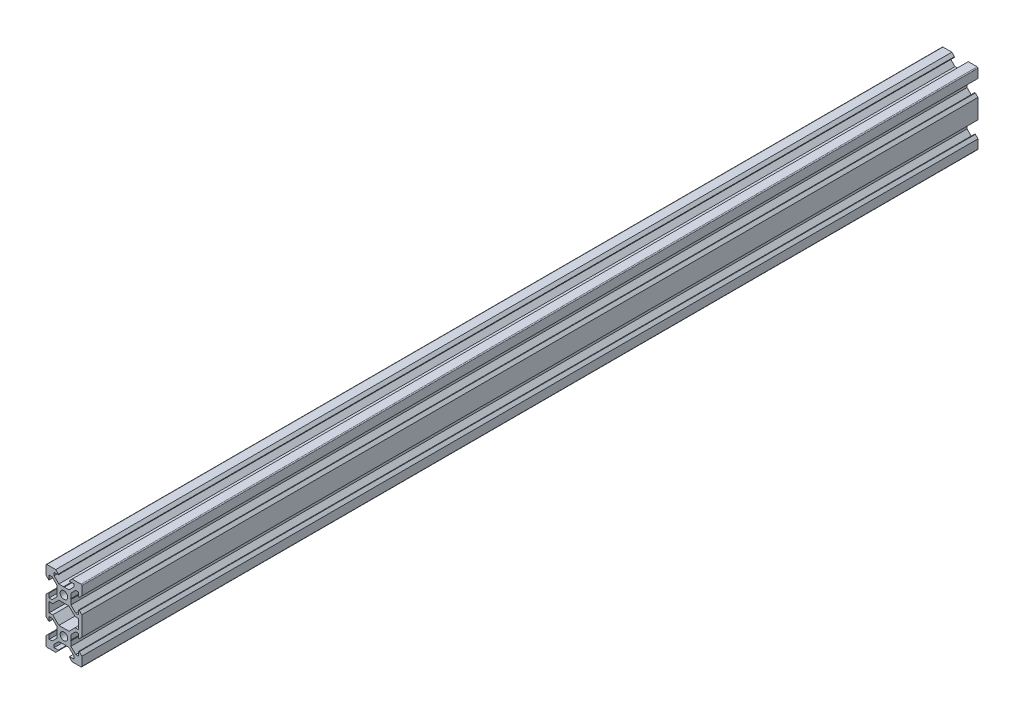
from build123d import *

# Parameters (mm, degrees)
SKETCH1_R           = 2.1
BOSS_EXTRUDE1_DEPTH = 500


with BuildPart() as part:
    # Sketch1 → Boss-Extrude1 (new body)
    with BuildSketch(Plane.XY):
        with BuildLine():
            Line((4.58, -20), (9.5, -20))
            ThreePointArc((9.5, -20), (9.853553391, -19.853553391), (10, -19.5))
            Line((10, -19.5), (10, -14.58))
            Line((10, -14.58), (8.545, -13.125))
            Line((8.545, -13.125), (8.2, -13.125))
            Line((8.2, -13.125), (8.2, -15.5))
            Line((8.2, -15.5), (6.560660172, -15.5))
            Line((6.560660172, -15.5), (3.9, -12.839339828))
            Line((3.9, -12.839339828), (3.9, -10.21))
            Line((3.9, -10.21), (3.69, -10))
            Line((3.69, -10), (3.9, -9.79))
            Line((3.9, -9.79), (3.9, -7.160660172))
            Line((3.9, -7.160660172), (6.560660172, -4.5))
            Line((6.560660172, -4.5), (8.2, -4.5))
            Line((8.2, -4.5), (8.2, -6.875))
            Line((8.2, -6.875), (8.545, -6.875))
            Line((8.545, -6.875), (10, -5.42))
            Line((10, -5.42), (10, 5.42))
            Line((10, 5.42), (8.545, 6.875))
            Line((8.545, 6.875), (8.2, 6.875))
            Line((8.2, 6.875), (8.2, 4.5))
            Line((8.2, 4.5), (6.560660172, 4.5))
            Line((6.560660172, 4.5), (3.9, 7.160660172))
            Line((3.9, 7.160660172), (3.9, 9.79))
            Line((3.9, 9.79), (3.69, 10))
            Line((3.69, 10), (3.9, 10.21))
            Line((3.9, 10.21), (3.9, 12.839339828))
            Line((3.9, 12.839339828), (6.560660172, 15.5))
            Line((6.560660172, 15.5), (8.2, 15.5))
            Line((8.2, 15.5), (8.2, 13.125))
            Line((8.2, 13.125), (8.545, 13.125))
            Line((8.545, 13.125), (10, 14.58))
            Line((10, 14.58), (10, 19.5))
            ThreePointArc((10, 19.5), (9.853553391, 19.853553391), (9.5, 20))
            Line((9.5, 20), (4.58, 20))
            Line((4.58, 20), (3.125, 18.545))
            Line((3.125, 18.545), (3.125, 18.2))
            Line((3.125, 18.2), (5.5, 18.2))
            Line((5.5, 18.2), (5.5, 16.560660172))
            Line((5.5, 16.560660172), (2.839339828, 13.9))
            Line((2.839339828, 13.9), (0.21, 13.9))
            Line((0.21, 13.9), (0, 13.69))
            Line((0, 13.69), (-0.21, 13.9))
            Line((-0.21, 13.9), (-2.839339828, 13.9))
            Line((-2.839339828, 13.9), (-5.5, 16.560660172))
            Line((-5.5, 16.560660172), (-5.5, 18.2))
            Line((-5.5, 18.2), (-3.125, 18.2))
            Line((-3.125, 18.2), (-3.125, 18.545))
            Line((-3.125, 18.545), (-4.58, 20))
            Line((-4.58, 20), (-9.5, 20))
            ThreePointArc((-9.5, 20), (-9.853553391, 19.853553391), (-10, 19.5))
            Line((-10, 19.5), (-10, 14.58))
            Line((-10, 14.58), (-8.545, 13.125))
            Line((-8.545, 13.125), (-8.2, 13.125))
            Line((-8.2, 13.125), (-8.2, 15.5))
            Line((-8.2, 15.5), (-6.560660172, 15.5))
            Line((-6.560660172, 15.5), (-3.9, 12.839339828))
            Line((-3.9, 12.839339828), (-3.9, 10.21))
            Line((-3.9, 10.21), (-3.69, 10))
            Line((-3.69, 10), (-3.9, 9.79))
            Line((-3.9, 9.79), (-3.9, 7.160660172))
            Line((-3.9, 7.160660172), (-6.560660172, 4.5))
            Line((-6.560660172, 4.5), (-8.2, 4.5))
            Line((-8.2, 4.5), (-8.2, 6.875))
            Line((-8.2, 6.875), (-8.545, 6.875))
            Line((-8.545, 6.875), (-10, 5.42))
            Line((-10, 5.42), (-10, -5.42))
            Line((-10, -5.42), (-8.545, -6.875))
            Line((-8.545, -6.875), (-8.2, -6.875))
            Line((-8.2, -6.875), (-8.2, -4.5))
            Line((-8.2, -4.5), (-6.560660172, -4.5))
            Line((-6.560660172, -4.5), (-3.9, -7.160660172))
            Line((-3.9, -7.160660172), (-3.9, -9.79))
            Line((-3.9, -9.79), (-3.69, -10))
            Line((-3.69, -10), (-3.9, -10.21))
            Line((-3.9, -10.21), (-3.9, -12.839339828))
            Line((-3.9, -12.839339828), (-6.560660172, -15.5))
            Line((-6.560660172, -15.5), (-8.2, -15.5))
            Line((-8.2, -15.5), (-8.2, -13.125))
            Line((-8.2, -13.125), (-8.545, -13.125))
            Line((-8.545, -13.125), (-10, -14.58))
            Line((-10, -14.58), (-10, -19.5))
            ThreePointArc((-10, -19.5), (-9.853553391, -19.853553391), (-9.5, -20))
            Line((-9.5, -20), (-4.58, -20))
            Line((-4.58, -20), (-3.125, -18.545))
            Line((-3.125, -18.545), (-3.125, -18.2))
            Line((-3.125, -18.2), (-5.5, -18.2))
            Line((-5.5, -18.2), (-5.5, -16.560660172))
            Line((-5.5, -16.560660172), (-2.839339828, -13.9))
            Line((-2.839339828, -13.9), (-0.21, -13.9))
            Line((-0.21, -13.9), (0, -13.69))
            Line((0, -13.69), (0.21, -13.9))
            Line((0.21, -13.9), (2.839339828, -13.9))
            Line((2.839339828, -13.9), (5.5, -16.560660172))
            Line((5.5, -16.560660172), (5.5, -18.2))
            Line((5.5, -18.2), (3.125, -18.2))
            Line((3.125, -18.2), (3.125, -18.545))
            Line((3.125, -18.545), (4.58, -20))
        make_face()
        with Locations((0, -10)):
            Circle(SKETCH1_R, mode=Mode.SUBTRACT)
        Polygon((-6.239339828, -2.7), (-8.2, -2.7), (-8.2, 2.7), (-6.239339828, 2.7), (-2.839339828, 6.1), (2.839339828, 6.1), (6.239339828, 2.7), (8.2, 2.7), (8.2, -2.7), (6.239339828, -2.7), (2.839339828, -6.1), (-2.839339828, -6.1), align=None, mode=Mode.SUBTRACT)
        with Locations((0, 10)):
            Circle(SKETCH1_R, mode=Mode.SUBTRACT)
    extrude(amount=BOSS_EXTRUDE1_DEPTH)


solid = part.part
